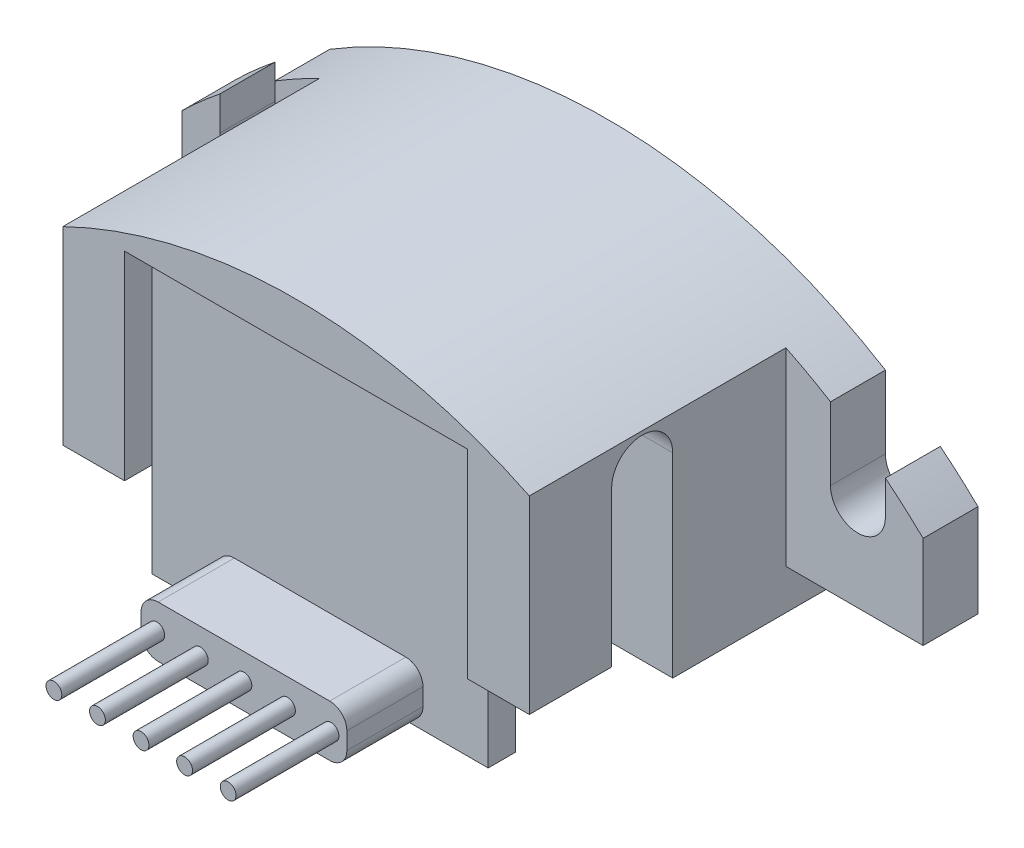
from build123d import *

# Parameters (mm, degrees)
BOSS_EXTRU_1_DEPTH           = 1.6
BOSS_EXTRU_2_DEPTH           = 7.48
ESQUISSE3_W                  = 10
ESQUISSE3_H                  = 5.8
ENL_V_MAT_EXTRU_2_DEPTH      = 1.5
ENL_V_MAT_EXTRU_3_DEPTH      = 18.6
ESQUISSE5_R                  = 1
BOSS_EXTRU_3_DEPTH           = 0.8
ESQUISSE8_W                  = 0.23
ESQUISSE8_H                  = 6.92
R_P_TITION_LIN_AIRE1_COUNT   = 3
R_P_TITION_LIN_AIRE1_PITCH   = 1.27
R_P_TITION_LIN_AIRE1_2_COUNT = 3
R_P_TITION_LIN_AIRE1_2_PITCH = 1.27
BOSS_EXTRU_4_DEPTH           = 0.8
ESQUISSE11_W                 = 13.6
ESQUISSE11_H                 = 1.17
BOSS_EXTRU_5_DEPTH           = 4.9
BOSS_EXTRU_6_DEPTH           = 2.22


with BuildPart() as part:
    # Esquisse1 → Boss.-Extru.1 (new body)
    with BuildSketch(Plane.XY):
        with BuildLine():
            Line((-10.8, 0.018003418), (-10.8, -2.69))
            Line((-10.8, -2.69), (10.8, -2.69))
            Line((10.8, -2.69), (10.8, 0.018003418))
            ThreePointArc((10.8, 0.018003418), (10.261507275, 0.516861385), (9.7, 0.989665008))
            Line((9.7, 0.989665008), (9.7, 0))
            ThreePointArc((9.7, 0), (8.9, -0.8), (8.1, 0))
            Line((8.1, 0), (8.1, 2.115142829))
            ThreePointArc((8.1, 2.115142829), (0, 4.4), (-8.1, 2.115142829))
            Line((-8.1, 2.115142829), (-8.1, 0))
            ThreePointArc((-8.1, 0), (-8.9, -0.8), (-9.7, 0))
            Line((-9.7, 0), (-9.7, 0.989665008))
            ThreePointArc((-9.7, 0.989665008), (-10.261507275, 0.516861385), (-10.8, 0.018003418))
        make_face()
    extrude(amount=BOSS_EXTRU_1_DEPTH)

    # Esquisse2 → Boss.-Extru.2 (add)
    with BuildSketch(Plane.XY.offset(1.6)):
        with BuildLine():
            Line((-6.8, 2.828747252), (-6.8, -2.69))
            Line((-6.8, -2.69), (6.8, -2.69))
            Line((6.8, -2.69), (6.8, 2.828747252))
            ThreePointArc((6.8, 2.828747252), (0, 4.4), (-6.8, 2.828747252))
        make_face()
    extrude(amount=BOSS_EXTRU_2_DEPTH)

    # Esquisse3 → Enlèv. mat.-Extru.2 (cut)
    with BuildSketch(Plane.XY.offset(9.08)):
        with Locations((0, 0.21)):
            Rectangle(ESQUISSE3_W, ESQUISSE3_H)
    extrude(amount=-ENL_V_MAT_EXTRU_2_DEPTH, mode=Mode.SUBTRACT)

    # Esquisse4 → Enlèv. mat.-Extru.3 (cut, through all)
    with BuildSketch(Plane.ZY.offset(6.8)):
        with BuildLine():
            Line((4.9, -2.69), (4.9, 1.828747252))
            ThreePointArc((4.9, 1.828747252), (5.79, 2.718747252), (6.68, 1.828747252))
            Line((6.68, 1.828747252), (6.68, -2.69))
            ThreePointArc((6.68, -2.69), (5.79, -3.58), (4.9, -2.69))
        make_face()
    extrude(amount=-ENL_V_MAT_EXTRU_3_DEPTH, mode=Mode.SUBTRACT)

    # Esquisse5 → Boss.-Extru.3 (add)
    with BuildSketch(Plane(origin=(0, 0, 0), x_dir=(-1, 0, 0), z_dir=(0, 0, -1))):
        with Locations((6.3, 0)):
            Circle(ESQUISSE5_R)
        with Locations((-6.3, 0)):
            Circle(ESQUISSE5_R)
    extrude(amount=BOSS_EXTRU_3_DEPTH)



with BuildPart() as body_2:
    # Esquisse8 → Révolution1 (revolve)
    with BuildSketch(Plane(origin=(0, -4.49, 0), x_dir=(1, 0, 0), z_dir=(0, 1, 0))):
        with Locations((0.115, -10.14)):
            Rectangle(ESQUISSE8_W, ESQUISSE8_H)
    revolve(axis=Axis((0, -4.49, 7.58), (0, 0, 1)))


with BuildPart() as r_p_tition_lin_aire1_1:
    # Répétition linéaire1: pattern copy
    add(body_2.part.moved(Location(Vector(1, 0, 0) * (1 * R_P_TITION_LIN_AIRE1_PITCH))))


with BuildPart() as r_p_tition_lin_aire1_2:
    # Répétition linéaire1: pattern copy
    add(body_2.part.moved(Location(Vector(1, 0, 0) * (2 * R_P_TITION_LIN_AIRE1_PITCH))))


with BuildPart() as r_p_tition_lin_aire1_2_1:
    # R_p_tition lin_aire1 2: pattern copy
    add(body_2.part.moved(Location(Vector(-1, 0, 0) * (1 * R_P_TITION_LIN_AIRE1_2_PITCH))))


with BuildPart() as r_p_tition_lin_aire1_2_2:
    # R_p_tition lin_aire1 2: pattern copy
    add(body_2.part.moved(Location(Vector(-1, 0, 0) * (2 * R_P_TITION_LIN_AIRE1_2_PITCH))))


with BuildPart() as r_p_tition_lin_aire1_2_3:
    # R_p_tition lin_aire1 2: pattern copy
    add(r_p_tition_lin_aire1_1.part.moved(Location(Vector(-1, 0, 0) * (1 * R_P_TITION_LIN_AIRE1_2_PITCH))))


with BuildPart() as r_p_tition_lin_aire1_2_4:
    # R_p_tition lin_aire1 2: pattern copy
    add(r_p_tition_lin_aire1_1.part.moved(Location(Vector(-1, 0, 0) * (2 * R_P_TITION_LIN_AIRE1_2_PITCH))))


with BuildPart() as r_p_tition_lin_aire1_2_5:
    # R_p_tition lin_aire1 2: pattern copy
    add(r_p_tition_lin_aire1_2.part.moved(Location(Vector(-1, 0, 0) * (1 * R_P_TITION_LIN_AIRE1_2_PITCH))))


with BuildPart() as r_p_tition_lin_aire1_2_6:
    # R_p_tition lin_aire1 2: pattern copy
    add(r_p_tition_lin_aire1_2.part.moved(Location(Vector(-1, 0, 0) * (2 * R_P_TITION_LIN_AIRE1_2_PITCH))))


with BuildPart() as part_1:
    add(part.part)

    add(body_2.part)  # Boss.-Extru.4 merges body 2

    add(r_p_tition_lin_aire1_1.part)  # Boss.-Extru.4 merges Répétition linéaire1_1

    add(r_p_tition_lin_aire1_2.part)  # Boss.-Extru.4 merges Répétition linéaire1_2

    add(r_p_tition_lin_aire1_2_1.part)  # Boss.-Extru.4 merges Répétition linéaire1 2_1

    add(r_p_tition_lin_aire1_2_2.part)  # Boss.-Extru.4 merges Répétition linéaire1 2_2

    add(r_p_tition_lin_aire1_2_3.part)  # Boss.-Extru.4 merges Répétition linéaire1 2_3

    add(r_p_tition_lin_aire1_2_4.part)  # Boss.-Extru.4 merges Répétition linéaire1 2_4

    add(r_p_tition_lin_aire1_2_5.part)  # Boss.-Extru.4 merges Répétition linéaire1 2_5

    add(r_p_tition_lin_aire1_2_6.part)  # Boss.-Extru.4 merges Répétition linéaire1 2_6
    # Esquisse10 → Boss.-Extru.4 (add)
    with BuildSketch(Plane.XY.offset(7.58)):
        Polygon((-4.9, -2.59), (-4.9, -5.34), (4.9, -5.34), (4.9, -2.59), (4.9, 3.01), (-4.9, 3.01), align=None)
    extrude(amount=BOSS_EXTRU_4_DEPTH)

    # Esquisse11 → Boss.-Extru.5 (add)
    with BuildSketch(Plane(origin=(0, 0, 0), x_dir=(-1, 0, 0), z_dir=(0, 0, -1))):
        with Locations((0, -3.275)):
            Rectangle(ESQUISSE11_W, ESQUISSE11_H)
    extrude(amount=-BOSS_EXTRU_5_DEPTH)

    # Esquisse12 → Boss.-Extru.6 (add)
    with BuildSketch(Plane.XY.offset(8.38)):
        with BuildLine():
            Line((2.5, -5.24), (-2.5, -5.24))
            ThreePointArc((-2.5, -5.24), (-2.853553391, -5.093553391), (-3, -4.74))
            Line((-3, -4.74), (-3, -4.24))
            ThreePointArc((-3, -4.24), (-2.853553391, -3.886446609), (-2.5, -3.74))
            Line((-2.5, -3.74), (2.5, -3.74))
            ThreePointArc((2.5, -3.74), (2.853553391, -3.886446609), (3, -4.24))
            Line((3, -4.24), (3, -4.74))
            ThreePointArc((3, -4.74), (2.853553391, -5.093553391), (2.5, -5.24))
        make_face()
    extrude(amount=BOSS_EXTRU_6_DEPTH)


solid = part_1.part
